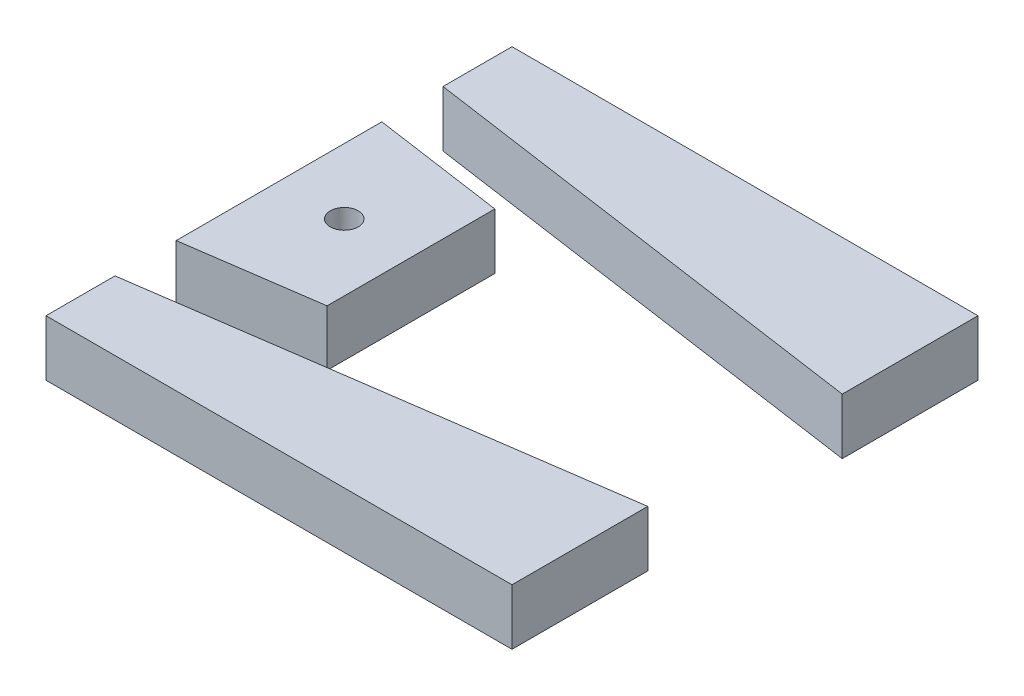
from build123d import *

# Parameters (mm, degrees)
SKETCH1_W             = 50
SKETCH1_H             = 50
BOSS_EXTRUDE1_DEPTH   = 6
CUT_EXTRUDE1_REACH    = 8
F_3_0MM_DOWEL_HOLE1_D = 3


with BuildPart() as part:
    # Sketch1 → Boss-Extrude1 (new body)
    with BuildSketch(Plane(origin=(0, 0, 0), x_dir=(1, 0, 0), z_dir=(0, 1, 0))):
        with Locations((1.150218805, 1.090402119)):
            Rectangle(SKETCH1_W, SKETCH1_H)
    extrude(amount=BOSS_EXTRUDE1_DEPTH)

    # Sketch2 → Cut-Extrude1 (cut, up to next)
    with BuildSketch(Plane(origin=(0, 6, 0), x_dir=(1, 0, 0), z_dir=(0, 1, 0)), mode=Mode.PRIVATE) as cut_extrude1_sk1:
        Polygon((-23.849781195, 18.689070655), (-23.849781195, 12.122649078), (-9.691499742, 10.093424527), (26.150218805, 4.956438412), (26.150218805, 11.522859989), align=None)
    cut_extrude1_tool1 = extrude(cut_extrude1_sk1.sketch, amount=-CUT_EXTRUDE1_REACH, mode=Mode.PRIVATE) & part.part
    add(cut_extrude1_tool1.solids().sort_by_distance((1.150219, 6, -11.822755))[0], mode=Mode.SUBTRACT)
    # Sketch2 → Cut-Extrude1 (cut, up to next)
    with BuildSketch(Plane(origin=(0, 6, 0), x_dir=(1, 0, 0), z_dir=(0, 1, 0)), mode=Mode.PRIVATE) as cut_extrude1_sk2:
        Polygon((-23.849781195, -9.941844841), (-23.849781195, -16.508266417), (26.150218805, -9.342055751), (26.150218805, -2.775634175), (-9.691499742, -7.91262029), align=None)
    cut_extrude1_tool2 = extrude(cut_extrude1_sk2.sketch, amount=-CUT_EXTRUDE1_REACH, mode=Mode.PRIVATE) & part.part
    add(cut_extrude1_tool2.solids().sort_by_distance((1.150219, 6, 9.64195))[0], mode=Mode.SUBTRACT)
    # Sketch2 → Cut-Extrude1 (cut, up to next)
    with BuildSketch(Plane(origin=(0, 6, 0), x_dir=(1, 0, 0), z_dir=(0, 1, 0)), mode=Mode.PRIVATE) as cut_extrude1_sk3:
        Polygon((-9.691499742, -7.91262029), (26.150218805, -2.775634175), (26.150218805, 4.956438412), (-9.691499742, 10.093424527), align=None)
    cut_extrude1_tool3 = extrude(cut_extrude1_sk3.sketch, amount=-CUT_EXTRUDE1_REACH, mode=Mode.PRIVATE) & part.part
    add(cut_extrude1_tool3.solids().sort_by_distance((5.844849, 6, -1.090402))[0], mode=Mode.SUBTRACT)

    # Ø3.0mm Dowel Hole1 (through all)
    with Locations(Plane(origin=(0, 6, 0), x_dir=(1, 0, 0), z_dir=(0, 1, 0))):
        with Locations((-16.849781195, 1.090402119)):
            Hole(F_3_0MM_DOWEL_HOLE1_D / 2)


solid = part.part
